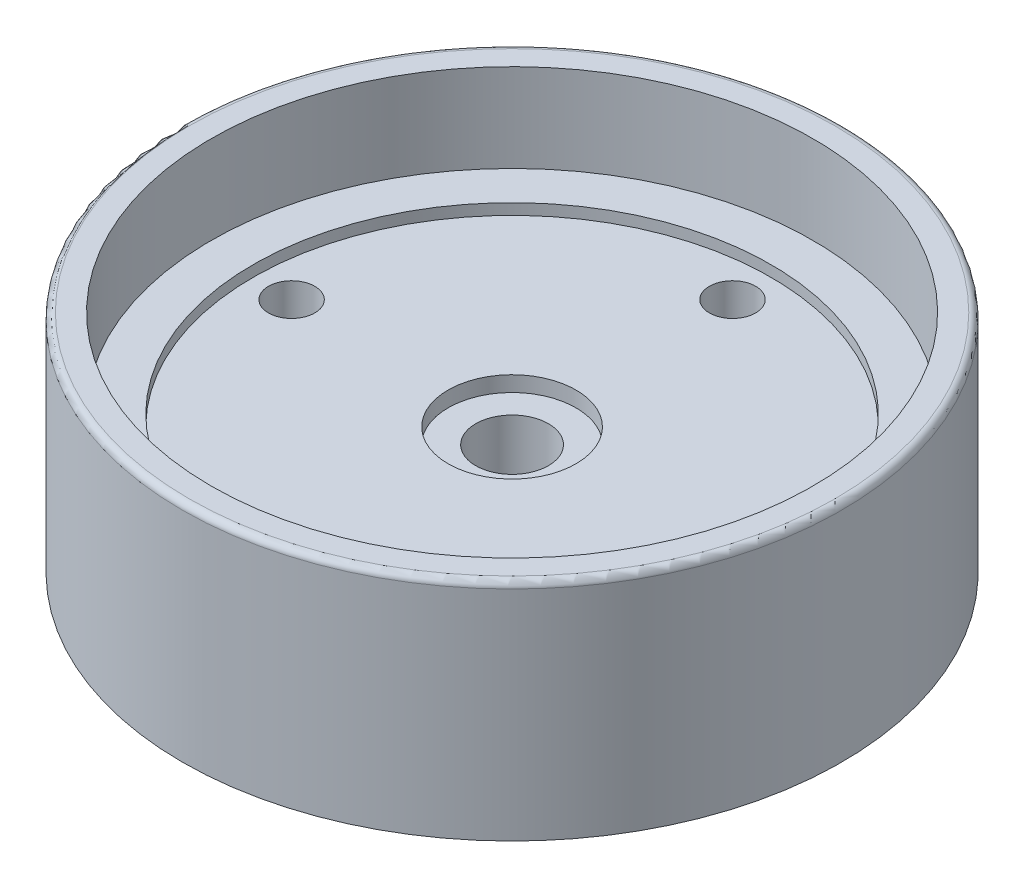
from build123d import *

# Parameters (mm, degrees)
SKETCH1_R           = 14.95
BOSS_EXTRUDE1_DEPTH = 6.2
SKETCH2_R           = 11.75
CUT_EXTRUDE1_DEPTH  = 0.5
SKETCH3_R           = 14.95
SKETCH3_R_2         = 13.65
BOSS_EXTRUDE2_DEPTH = 4
FILLET1_R           = 0.3
SKETCH4_R           = 1.65
CUT_EXTRUDE2_DEPTH  = 22.897374272
SKETCH18_R          = 2.9
CUT_EXTRUDE10_DEPTH = 0.7
SKETCH19_R          = 1.05
CUT_EXTRUDE11_DEPTH = 22.897374272


with BuildPart() as part:
    # Sketch1 → Boss-Extrude1 (new body)
    with BuildSketch(Plane(origin=(0, 0, 0), x_dir=(1, 0, 0), z_dir=(0, 1, 0))):
        Circle(SKETCH1_R)
    extrude(amount=BOSS_EXTRUDE1_DEPTH)

    # Sketch2 → Cut-Extrude1 (cut)
    with BuildSketch(Plane(origin=(0, 6.2, 0), x_dir=(1, 0, 0), z_dir=(0, 1, 0))):
        Circle(SKETCH2_R)
    extrude(amount=-CUT_EXTRUDE1_DEPTH, mode=Mode.SUBTRACT)

    # Sketch3 → Boss-Extrude2 (add)
    with BuildSketch(Plane(origin=(0, 6.2, 0), x_dir=(1, 0, 0), z_dir=(0, 1, 0))):
        Circle(SKETCH3_R)
        Circle(SKETCH3_R_2, mode=Mode.SUBTRACT)
    extrude(amount=BOSS_EXTRUDE2_DEPTH)

    # Fillet1
    fillet1_edges = [part.edges().sort_by_distance(p)[0] for p in [
        (-14.95, 10.2, 0),
    ]]
    fillet(fillet1_edges, radius=FILLET1_R)

    # Sketch4 → Cut-Extrude2 (cut, through all)
    with BuildSketch(Plane(origin=(0, 5.7, 0), x_dir=(1, 0, 0), z_dir=(0, 1, 0))):
        Circle(SKETCH4_R)
    extrude(amount=-CUT_EXTRUDE2_DEPTH, mode=Mode.SUBTRACT)

    # Sketch18 → Cut-Extrude10 (cut)
    with BuildSketch(Plane(origin=(0, 5.7, 0), x_dir=(1, 0, 0), z_dir=(0, 1, 0))):
        Circle(SKETCH18_R)
    extrude(amount=-CUT_EXTRUDE10_DEPTH, mode=Mode.SUBTRACT)

    # Sketch19 → Cut-Extrude11 (cut, through all)
    with BuildSketch(Plane(origin=(0, 5.7, 0), x_dir=(1, 0, 0), z_dir=(0, 1, 0))):
        with Locations((0, 10)):
            Circle(SKETCH19_R)
        with Locations((10, 0)):
            Circle(SKETCH19_R)
        with Locations((0, -10)):
            Circle(SKETCH19_R)
        with Locations((-10, 0)):
            Circle(SKETCH19_R)
    extrude(amount=-CUT_EXTRUDE11_DEPTH, mode=Mode.SUBTRACT)


solid = part.part
